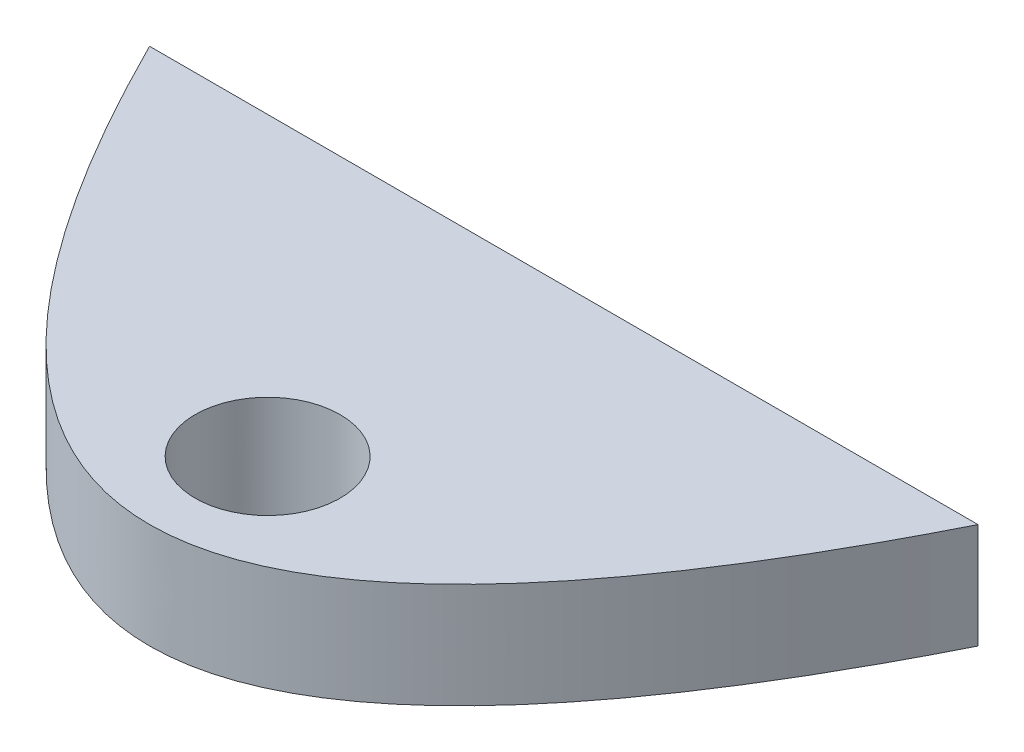
from build123d import *

# Parameters (mm, degrees)
BOSS_EXTRUDE1_DEPTH     = 300
SKETCH3_R               = 15.5
CUT_EXTRUDE1_DEPTH      = 23
CUT_EXTRUDE1_DEPTH_BACK = 23
SKETCH4_R               = 35
CUT_EXTRUDE3_DEPTH      = 300
SKETCH5_W               = 496.22566609
SKETCH5_H               = 70.680473068
SKETCH5_W_2             = 504.512342242
SKETCH5_H_2             = 238.363802277
CUT_EXTRUDE4_DEPTH      = 201.0000001


with BuildPart() as part:
    # Sketch1 → Boss-Extrude1 (new body)
    with BuildSketch(Plane(origin=(0, 0, 0), x_dir=(1, 0, 0), z_dir=(0, 1, 0))):
        with BuildLine():
            Line((-200, 1e-09), (200, 1e-09))
            add(Edge.make_bspline(
                [(-200, 1e-09), (0, -400.000000001), (200, 1e-09)],
                knots=[0.056028396, 0.056028396, 0.056028396, 0.943971604, 0.943971604, 0.943971604], degree=2))
        make_face()
    extrude(amount=BOSS_EXTRUDE1_DEPTH)

    # Sketch3 → Cut-Extrude1 (cut, two sides)
    with BuildSketch(Plane(origin=(0, 150, 0), x_dir=(1, 0, 0), z_dir=(0, 1, 0))) as cut_extrude1_sk:
        with Locations((0, -142.999999999)):
            Circle(SKETCH3_R)
    extrude(amount=CUT_EXTRUDE1_DEPTH, mode=Mode.SUBTRACT)
    extrude(cut_extrude1_sk.sketch, amount=-CUT_EXTRUDE1_DEPTH_BACK, mode=Mode.SUBTRACT)

    # Sketch4 → Cut-Extrude3 (cut)
    with BuildSketch(Plane(origin=(0, 173, 0), x_dir=(1, 0, 0), z_dir=(0, 1, 0))):
        with Locations((0, -142.999999999)):
            Circle(SKETCH4_R)
    cut_extrude3 = extrude(amount=CUT_EXTRUDE3_DEPTH, mode=Mode.SUBTRACT)

    # Mirror1: Cut-Extrude3 across plane
    add(cut_extrude3.mirror(Plane.ZX.offset(150)), mode=Mode.SUBTRACT)

    # Sketch5 → Cut-Extrude4 (cut, through all)
    with BuildSketch(Plane(origin=(0, 0, 0), x_dir=(-1, 0, 0), z_dir=(0, 0, -1))):
        with Locations((-4.143338076, 284.540236534)):
            Rectangle(SKETCH5_W, SKETCH5_H)
        with Locations((0, 79.218098862)):
            Rectangle(SKETCH5_W_2, SKETCH5_H_2)
    extrude(amount=-CUT_EXTRUDE4_DEPTH, mode=Mode.SUBTRACT)


solid = part.part
